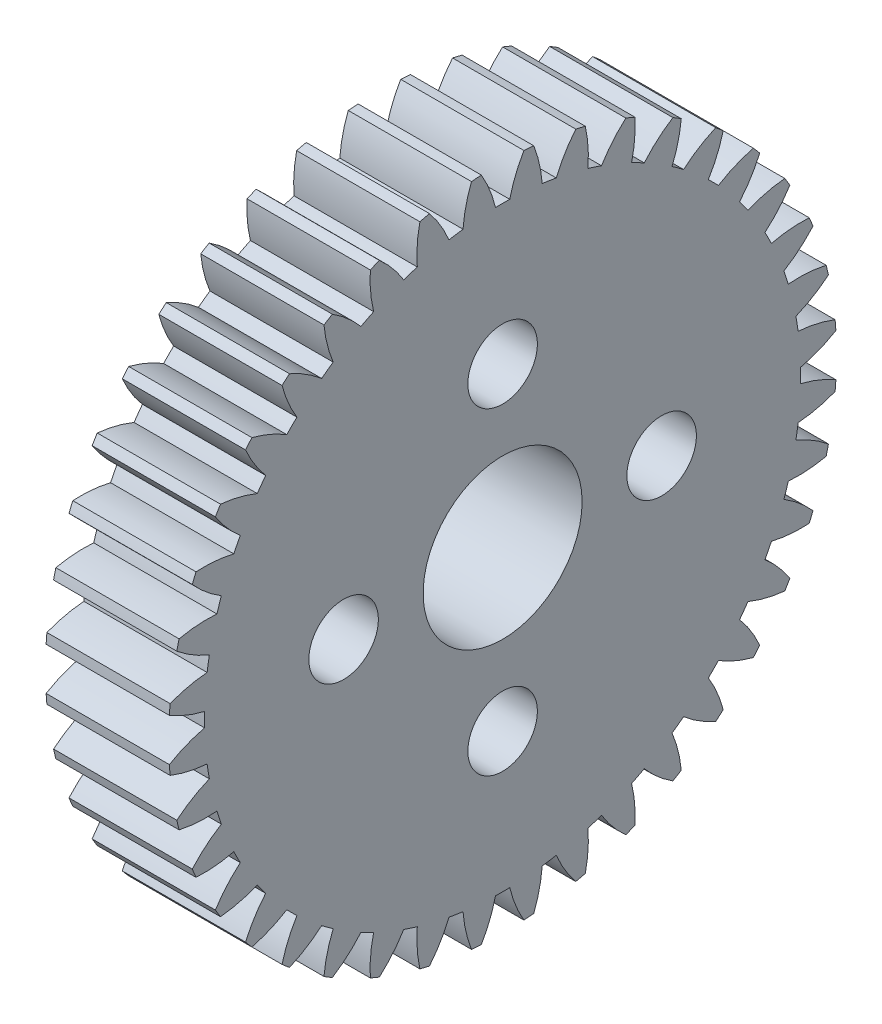
from build123d import *

# Parameters (mm, degrees)
SKETCH1_R           = 4
SKETCH1_R_2         = 1.75
BOSS_EXTRUDE1_DEPTH = 6.2


with BuildPart() as part:
    # Sketch1 → Boss-Extrude1 (new body)
    with BuildSketch(Plane(origin=(0, 0, 0), x_dir=(0, -1, 0), z_dir=(-1, 0, 0))):
        with BuildLine():
            ThreePointArc((-16.276318803, -4.161904158), (-15.328836725, -4.298843929), (-14.371528142, -4.292922065))
            ThreePointArc((-14.371528142, -4.292922065), (-14.264896688, -4.634945899), (-14.150126781, -4.974325389))
            ThreePointArc((-14.150126781, -4.974325389), (-14.928086477, -5.532226367), (-15.614124403, -6.199928961))
            ThreePointArc((-15.614124403, -6.199928961), (-15.521176146, -6.429081664), (-15.424865059, -6.656841436))
            ThreePointArc((-15.424865059, -6.656841436), (-14.467625957, -6.643876399), (-13.523029816, -6.488271387))
            ThreePointArc((-13.523029816, -6.488271387), (-13.364206856, -6.809403506), (-13.197759308, -7.126650702))
            ThreePointArc((-13.197759308, -7.126650702), (-13.878866089, -7.799382702), (-14.452006051, -8.566184746))
            ThreePointArc((-14.452006051, -8.566184746), (-14.324354761, -8.777975887), (-14.193599945, -8.987865186))
            ThreePointArc((-14.193599945, -8.987865186), (-13.250174224, -8.825314583), (-12.341549615, -8.523857935))
            ThreePointArc((-12.341549615, -8.523857935), (-12.134445899, -8.816190999), (-11.920419201, -9.103494223))
            ThreePointArc((-11.920419201, -9.103494223), (-12.487901956, -9.874492351), (-12.934031347, -10.721512632))
            ThreePointArc((-12.934031347, -10.721512632), (-12.774820222, -10.910727212), (-12.612841295, -11.097577865))
            ThreePointArc((-12.612841295, -11.097577865), (-11.706459226, -10.789444232), (-10.856179504, -10.349558811))
            ThreePointArc((-10.856179504, -10.349558811), (-10.605894611, -10.605894611), (-10.349558811, -10.856179504))
            ThreePointArc((-10.349558811, -10.856179504), (-10.789444232, -11.706459226), (-11.097577865, -12.612841295))
            ThreePointArc((-11.097577865, -12.612841295), (-10.910727212, -12.774820222), (-10.721512632, -12.934031347))
            ThreePointArc((-10.721512632, -12.934031347), (-9.874492351, -12.487901956), (-9.103494223, -11.920419201))
            ThreePointArc((-9.103494223, -11.920419201), (-8.816190999, -12.134445899), (-8.523857935, -12.341549615))
            ThreePointArc((-8.523857935, -12.341549615), (-8.825314583, -13.250174224), (-8.987865186, -14.193599945))
            ThreePointArc((-8.987865186, -14.193599945), (-8.777975887, -14.324354761), (-8.566184746, -14.452006051))
            ThreePointArc((-8.566184746, -14.452006051), (-7.799382702, -13.878866089), (-7.126650702, -13.197759308))
            ThreePointArc((-7.126650702, -13.197759308), (-6.809403506, -13.364206856), (-6.488271387, -13.523029816))
            ThreePointArc((-6.488271387, -13.523029816), (-6.643876399, -14.467625957), (-6.656841436, -15.424865059))
            ThreePointArc((-6.656841436, -15.424865059), (-6.429081664, -15.521176146), (-6.199928961, -15.614124403))
            ThreePointArc((-6.199928961, -15.614124403), (-5.532226367, -14.928086477), (-4.974325389, -14.150126781))
            ThreePointArc((-4.974325389, -14.150126781), (-4.634945899, -14.264896688), (-4.292922065, -14.371528142))
            ThreePointArc((-4.292922065, -14.371528142), (-4.298843929, -15.328836725), (-4.161904158, -16.276318803))
            ThreePointArc((-4.161904158, -16.276318803), (-3.921882113, -16.335814663), (-3.68101035, -16.391771192))
            ThreePointArc((-3.68101035, -16.391771192), (-3.128848258, -15.609727833), (-2.699515676, -14.754071171))
            ThreePointArc((-2.699515676, -14.754071171), (-2.346360541, -14.814337421), (-1.991866754, -14.866151749))
            ThreePointArc((-1.991866754, -14.866151749), (-1.847959654, -15.812600658), (-1.564486987, -16.72699556))
            ThreePointArc((-1.564486987, -16.72699556), (-1.318112808, -16.748211207), (-1.071453046, -16.765798173))
            ThreePointArc((-1.071453046, -16.765798173), (-0.648427521, -15.907005884), (-0.358234928, -14.994721362))
            ThreePointArc((-0.358234928, -14.994721362), (0, -14.999), (0.358234928, -14.994721362))
            ThreePointArc((0.358234928, -14.994721362), (0.648427521, -15.907005884), (1.071453046, -16.765798173))
            ThreePointArc((1.071453046, -16.765798173), (1.318112808, -16.748211207), (1.564486987, -16.72699556))
            ThreePointArc((1.564486987, -16.72699556), (1.847959654, -15.812600658), (1.991866754, -14.866151749))
            ThreePointArc((1.991866754, -14.866151749), (2.346360541, -14.814337421), (2.699515676, -14.754071171))
            ThreePointArc((2.699515676, -14.754071171), (3.128848258, -15.609727833), (3.68101035, -16.391771192))
            ThreePointArc((3.68101035, -16.391771192), (3.921882113, -16.335814663), (4.161904158, -16.276318803))
            ThreePointArc((4.161904158, -16.276318803), (4.298843929, -15.328836725), (4.292922065, -14.371528142))
            ThreePointArc((4.292922065, -14.371528142), (4.634945899, -14.264896688), (4.974325389, -14.150126781))
            ThreePointArc((4.974325389, -14.150126781), (5.532226367, -14.928086477), (6.199928961, -15.614124403))
            ThreePointArc((6.199928961, -15.614124403), (6.429081664, -15.521176146), (6.656841436, -15.424865059))
            ThreePointArc((6.656841436, -15.424865059), (6.643876399, -14.467625957), (6.488271387, -13.523029816))
            ThreePointArc((6.488271387, -13.523029816), (6.809403506, -13.364206856), (7.126650702, -13.197759308))
            ThreePointArc((7.126650702, -13.197759308), (7.799382702, -13.878866089), (8.566184746, -14.452006051))
            ThreePointArc((8.566184746, -14.452006051), (8.777975887, -14.324354761), (8.987865186, -14.193599945))
            ThreePointArc((8.987865186, -14.193599945), (8.825314583, -13.250174224), (8.523857935, -12.341549615))
            ThreePointArc((8.523857935, -12.341549615), (8.816190999, -12.134445899), (9.103494223, -11.920419201))
            ThreePointArc((9.103494223, -11.920419201), (9.874492351, -12.487901956), (10.721512632, -12.934031347))
            ThreePointArc((10.721512632, -12.934031347), (10.910727212, -12.774820222), (11.097577865, -12.612841295))
            ThreePointArc((11.097577865, -12.612841295), (10.789444232, -11.706459226), (10.349558811, -10.856179504))
            ThreePointArc((10.349558811, -10.856179504), (10.605894611, -10.605894611), (10.856179504, -10.349558811))
            ThreePointArc((10.856179504, -10.349558811), (11.706459226, -10.789444232), (12.612841295, -11.097577865))
            ThreePointArc((12.612841295, -11.097577865), (12.774820222, -10.910727212), (12.934031347, -10.721512632))
            ThreePointArc((12.934031347, -10.721512632), (12.487901956, -9.874492351), (11.920419201, -9.103494223))
            ThreePointArc((11.920419201, -9.103494223), (12.134445899, -8.816190999), (12.341549615, -8.523857935))
            ThreePointArc((12.341549615, -8.523857935), (13.250174224, -8.825314583), (14.193599945, -8.987865186))
            ThreePointArc((14.193599945, -8.987865186), (14.324354761, -8.777975887), (14.452006051, -8.566184746))
            ThreePointArc((14.452006051, -8.566184746), (13.878866089, -7.799382702), (13.197759308, -7.126650702))
            ThreePointArc((13.197759308, -7.126650702), (13.364206856, -6.809403506), (13.523029816, -6.488271387))
            ThreePointArc((13.523029816, -6.488271387), (14.467625957, -6.643876399), (15.424865059, -6.656841436))
            ThreePointArc((15.424865059, -6.656841436), (15.521176146, -6.429081664), (15.614124403, -6.199928961))
            ThreePointArc((15.614124403, -6.199928961), (14.928086477, -5.532226367), (14.150126781, -4.974325389))
            ThreePointArc((14.150126781, -4.974325389), (14.264896688, -4.634945899), (14.371528142, -4.292922065))
            ThreePointArc((14.371528142, -4.292922065), (15.328836725, -4.298843929), (16.276318803, -4.161904158))
            ThreePointArc((16.276318803, -4.161904158), (16.335814663, -3.921882113), (16.391771192, -3.68101035))
            ThreePointArc((16.391771192, -3.68101035), (15.609727833, -3.128848258), (14.754071171, -2.699515676))
            ThreePointArc((14.754071171, -2.699515676), (14.814337421, -2.346360541), (14.866151749, -1.991866754))
            ThreePointArc((14.866151749, -1.991866754), (15.812600658, -1.847959654), (16.72699556, -1.564486987))
            ThreePointArc((16.72699556, -1.564486987), (16.748211207, -1.318112808), (16.765798173, -1.071453046))
            ThreePointArc((16.765798173, -1.071453046), (15.907005884, -0.648427521), (14.994721362, -0.358234928))
            ThreePointArc((14.994721362, -0.358234928), (14.999, 0), (14.994721362, 0.358234928))
            ThreePointArc((14.994721362, 0.358234928), (15.907005884, 0.648427521), (16.765798173, 1.071453046))
            ThreePointArc((16.765798173, 1.071453046), (16.748211207, 1.318112808), (16.72699556, 1.564486987))
            ThreePointArc((16.72699556, 1.564486987), (15.812600658, 1.847959654), (14.866151749, 1.991866754))
            ThreePointArc((14.866151749, 1.991866754), (14.814337421, 2.346360541), (14.754071171, 2.699515676))
            ThreePointArc((14.754071171, 2.699515676), (15.609727833, 3.128848258), (16.391771192, 3.68101035))
            ThreePointArc((16.391771192, 3.68101035), (16.335814663, 3.921882113), (16.276318803, 4.161904158))
            ThreePointArc((16.276318803, 4.161904158), (15.328836725, 4.298843929), (14.371528142, 4.292922065))
            ThreePointArc((14.371528142, 4.292922065), (14.264896688, 4.634945899), (14.150126781, 4.974325389))
            ThreePointArc((14.150126781, 4.974325389), (14.928086477, 5.532226367), (15.614124403, 6.199928961))
            ThreePointArc((15.614124403, 6.199928961), (15.521176146, 6.429081664), (15.424865059, 6.656841436))
            ThreePointArc((15.424865059, 6.656841436), (14.467625957, 6.643876399), (13.523029816, 6.488271387))
            ThreePointArc((13.523029816, 6.488271387), (13.364206856, 6.809403506), (13.197759308, 7.126650702))
            ThreePointArc((13.197759308, 7.126650702), (13.878866089, 7.799382702), (14.452006051, 8.566184746))
            ThreePointArc((14.452006051, 8.566184746), (14.324354761, 8.777975887), (14.193599945, 8.987865186))
            ThreePointArc((14.193599945, 8.987865186), (13.250174224, 8.825314583), (12.341549615, 8.523857935))
            ThreePointArc((12.341549615, 8.523857935), (12.134445899, 8.816190999), (11.920419201, 9.103494223))
            ThreePointArc((11.920419201, 9.103494223), (12.487901956, 9.874492351), (12.934031347, 10.721512632))
            ThreePointArc((12.934031347, 10.721512632), (12.774820222, 10.910727212), (12.612841295, 11.097577865))
            ThreePointArc((12.612841295, 11.097577865), (11.706459226, 10.789444232), (10.856179504, 10.349558811))
            ThreePointArc((10.856179504, 10.349558811), (10.605894611, 10.605894611), (10.349558811, 10.856179504))
            ThreePointArc((10.349558811, 10.856179504), (10.789444232, 11.706459226), (11.097577865, 12.612841295))
            ThreePointArc((11.097577865, 12.612841295), (10.910727212, 12.774820222), (10.721512632, 12.934031347))
            ThreePointArc((10.721512632, 12.934031347), (9.874492351, 12.487901956), (9.103494223, 11.920419201))
            ThreePointArc((9.103494223, 11.920419201), (8.816190999, 12.134445899), (8.523857935, 12.341549615))
            ThreePointArc((8.523857935, 12.341549615), (8.825314583, 13.250174224), (8.987865186, 14.193599945))
            ThreePointArc((8.987865186, 14.193599945), (8.777975887, 14.324354761), (8.566184746, 14.452006051))
            ThreePointArc((8.566184746, 14.452006051), (7.799382702, 13.878866089), (7.126650702, 13.197759308))
            ThreePointArc((7.126650702, 13.197759308), (6.809403506, 13.364206856), (6.488271387, 13.523029816))
            ThreePointArc((6.488271387, 13.523029816), (6.643876399, 14.467625957), (6.656841436, 15.424865059))
            ThreePointArc((6.656841436, 15.424865059), (6.429081664, 15.521176146), (6.199928961, 15.614124403))
            ThreePointArc((6.199928961, 15.614124403), (5.532226367, 14.928086477), (4.974325389, 14.150126781))
            ThreePointArc((4.974325389, 14.150126781), (4.634945899, 14.264896688), (4.292922065, 14.371528142))
            ThreePointArc((4.292922065, 14.371528142), (4.298843929, 15.328836725), (4.161904158, 16.276318803))
            ThreePointArc((4.161904158, 16.276318803), (3.921882113, 16.335814663), (3.68101035, 16.391771192))
            ThreePointArc((3.68101035, 16.391771192), (3.128848258, 15.609727833), (2.699515676, 14.754071171))
            ThreePointArc((2.699515676, 14.754071171), (2.346360541, 14.814337421), (1.991866754, 14.866151749))
            ThreePointArc((1.991866754, 14.866151749), (1.847959654, 15.812600658), (1.564486987, 16.72699556))
            ThreePointArc((1.564486987, 16.72699556), (1.318112808, 16.748211207), (1.071453046, 16.765798173))
            ThreePointArc((1.071453046, 16.765798173), (0.648427521, 15.907005884), (0.358234928, 14.994721362))
            ThreePointArc((0.358234928, 14.994721362), (0, 14.999), (-0.358234928, 14.994721362))
            ThreePointArc((-0.358234928, 14.994721362), (-0.648427521, 15.907005884), (-1.071453046, 16.765798173))
            ThreePointArc((-1.071453046, 16.765798173), (-1.318112808, 16.748211207), (-1.564486987, 16.72699556))
            ThreePointArc((-1.564486987, 16.72699556), (-1.847959654, 15.812600658), (-1.991866754, 14.866151749))
            ThreePointArc((-1.991866754, 14.866151749), (-2.346360541, 14.814337421), (-2.699515676, 14.754071171))
            ThreePointArc((-2.699515676, 14.754071171), (-3.128848258, 15.609727833), (-3.68101035, 16.391771192))
            ThreePointArc((-3.68101035, 16.391771192), (-3.921882113, 16.335814663), (-4.161904158, 16.276318803))
            ThreePointArc((-4.161904158, 16.276318803), (-4.298843929, 15.328836725), (-4.292922065, 14.371528142))
            ThreePointArc((-4.292922065, 14.371528142), (-4.634945899, 14.264896688), (-4.974325389, 14.150126781))
            ThreePointArc((-4.974325389, 14.150126781), (-5.532226367, 14.928086477), (-6.199928961, 15.614124403))
            ThreePointArc((-6.199928961, 15.614124403), (-6.429081664, 15.521176146), (-6.656841436, 15.424865059))
            ThreePointArc((-6.656841436, 15.424865059), (-6.643876399, 14.467625957), (-6.488271387, 13.523029816))
            ThreePointArc((-6.488271387, 13.523029816), (-6.809403506, 13.364206856), (-7.126650702, 13.197759308))
            ThreePointArc((-7.126650702, 13.197759308), (-7.799382702, 13.878866089), (-8.566184746, 14.452006051))
            ThreePointArc((-8.566184746, 14.452006051), (-8.777975887, 14.324354761), (-8.987865186, 14.193599945))
            ThreePointArc((-8.987865186, 14.193599945), (-8.825314583, 13.250174224), (-8.523857935, 12.341549615))
            ThreePointArc((-8.523857935, 12.341549615), (-8.816190999, 12.134445899), (-9.103494223, 11.920419201))
            ThreePointArc((-9.103494223, 11.920419201), (-9.874492351, 12.487901956), (-10.721512632, 12.934031347))
            ThreePointArc((-10.721512632, 12.934031347), (-10.910727212, 12.774820222), (-11.097577865, 12.612841295))
            ThreePointArc((-11.097577865, 12.612841295), (-10.789444232, 11.706459226), (-10.349558811, 10.856179504))
            ThreePointArc((-10.349558811, 10.856179504), (-10.605894611, 10.605894611), (-10.856179504, 10.349558811))
            ThreePointArc((-10.856179504, 10.349558811), (-11.706459226, 10.789444232), (-12.612841295, 11.097577865))
            ThreePointArc((-12.612841295, 11.097577865), (-12.774820222, 10.910727212), (-12.934031347, 10.721512632))
            ThreePointArc((-12.934031347, 10.721512632), (-12.487901956, 9.874492351), (-11.920419201, 9.103494223))
            ThreePointArc((-11.920419201, 9.103494223), (-12.134445899, 8.816190999), (-12.341549615, 8.523857935))
            ThreePointArc((-12.341549615, 8.523857935), (-13.250174224, 8.825314583), (-14.193599945, 8.987865186))
            ThreePointArc((-14.193599945, 8.987865186), (-14.324354761, 8.777975887), (-14.452006051, 8.566184746))
            ThreePointArc((-14.452006051, 8.566184746), (-13.878866089, 7.799382702), (-13.197759308, 7.126650702))
            ThreePointArc((-13.197759308, 7.126650702), (-13.364206856, 6.809403506), (-13.523029816, 6.488271387))
            ThreePointArc((-13.523029816, 6.488271387), (-14.467625957, 6.643876399), (-15.424865059, 6.656841436))
            ThreePointArc((-15.424865059, 6.656841436), (-15.521176146, 6.429081664), (-15.614124403, 6.199928961))
            ThreePointArc((-15.614124403, 6.199928961), (-14.928086477, 5.532226367), (-14.150126781, 4.974325389))
            ThreePointArc((-14.150126781, 4.974325389), (-14.264896688, 4.634945899), (-14.371528142, 4.292922065))
            ThreePointArc((-14.371528142, 4.292922065), (-15.328836725, 4.298843929), (-16.276318803, 4.161904158))
            ThreePointArc((-16.276318803, 4.161904158), (-16.335814663, 3.921882113), (-16.391771192, 3.68101035))
            ThreePointArc((-16.391771192, 3.68101035), (-15.609727833, 3.128848258), (-14.754071171, 2.699515676))
            ThreePointArc((-14.754071171, 2.699515676), (-14.814337421, 2.346360541), (-14.866151749, 1.991866754))
            ThreePointArc((-14.866151749, 1.991866754), (-15.812600658, 1.847959654), (-16.72699556, 1.564486987))
            ThreePointArc((-16.72699556, 1.564486987), (-16.748211207, 1.318112808), (-16.765798173, 1.071453046))
            ThreePointArc((-16.765798173, 1.071453046), (-15.907005884, 0.648427521), (-14.994721362, 0.358234928))
            ThreePointArc((-14.994721362, 0.358234928), (-14.999, 0), (-14.994721362, -0.358234928))
            ThreePointArc((-14.994721362, -0.358234928), (-15.907005884, -0.648427521), (-16.765798173, -1.071453046))
            ThreePointArc((-16.765798173, -1.071453046), (-16.748211207, -1.318112808), (-16.72699556, -1.564486987))
            ThreePointArc((-16.72699556, -1.564486987), (-15.812600658, -1.847959654), (-14.866151749, -1.991866754))
            ThreePointArc((-14.866151749, -1.991866754), (-14.814337421, -2.346360541), (-14.754071171, -2.699515676))
            ThreePointArc((-14.754071171, -2.699515676), (-15.609727833, -3.128848258), (-16.391771192, -3.68101035))
            ThreePointArc((-16.391771192, -3.68101035), (-16.335814663, -3.921882113), (-16.276318803, -4.161904158))
        make_face()
        Circle(SKETCH1_R, mode=Mode.SUBTRACT)
        with Locations((0, 8)):
            Circle(SKETCH1_R_2, mode=Mode.SUBTRACT)
        with Locations((-8, 0)):
            Circle(SKETCH1_R_2, mode=Mode.SUBTRACT)
        with Locations((8, 0)):
            Circle(SKETCH1_R_2, mode=Mode.SUBTRACT)
        with Locations((0, -8)):
            Circle(SKETCH1_R_2, mode=Mode.SUBTRACT)
    extrude(amount=-BOSS_EXTRUDE1_DEPTH)


solid = part.part
